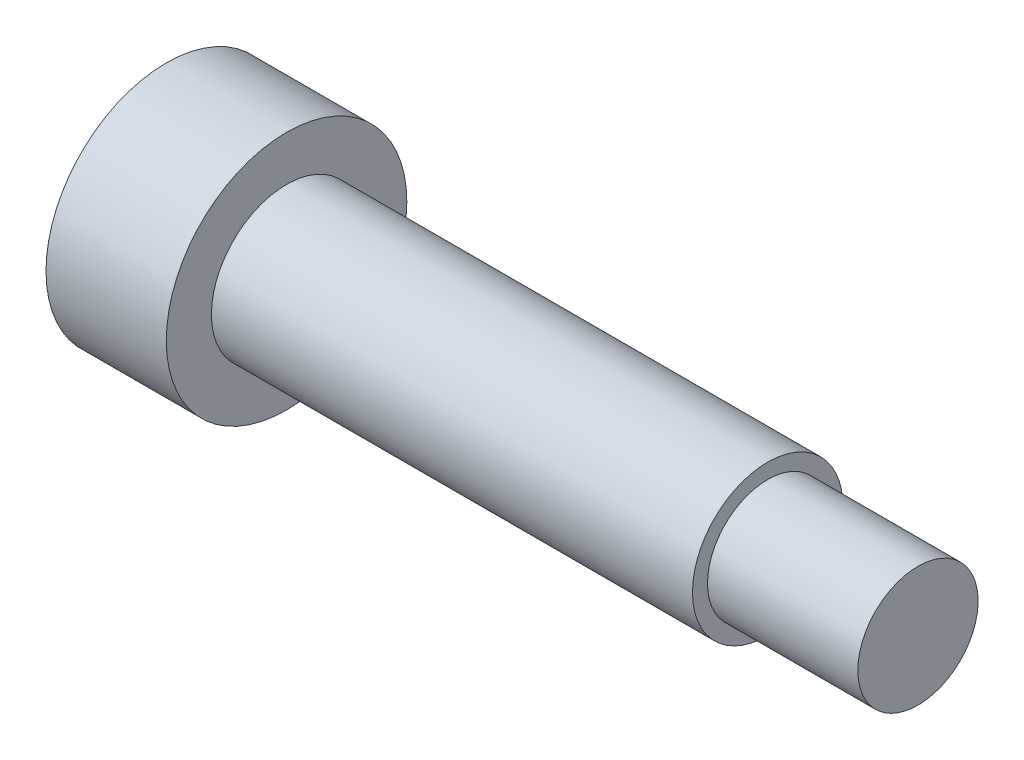
from build123d import *

# Parameters (mm, degrees)
CUT_EXTRUDE1_DEPTH = 1.5


with BuildPart() as part:
    # Sketch1 → Revolve1 (revolve)
    with BuildSketch(Plane.XY):
        Polygon((0, 0), (25, 0), (25, 2), (20, 2), (20, 2.5), (4, 2.5), (4, 4), (0, 4), align=None)
    revolve(axis=Axis((0, 0, 0), (1, 0, 0)))

    # Sketch2 → Cut-Extrude1 (cut)
    with BuildSketch(Plane.ZY):
        Polygon((-0.209897737, 1.428032308), (-1.341661125, 0.532239381), (-1.131763388, -0.895792927), (0.209897737, -1.428032308), (1.341661125, -0.532239381), (1.131763388, 0.895792927), align=None)
    extrude(amount=-CUT_EXTRUDE1_DEPTH, mode=Mode.SUBTRACT)


solid = part.part
